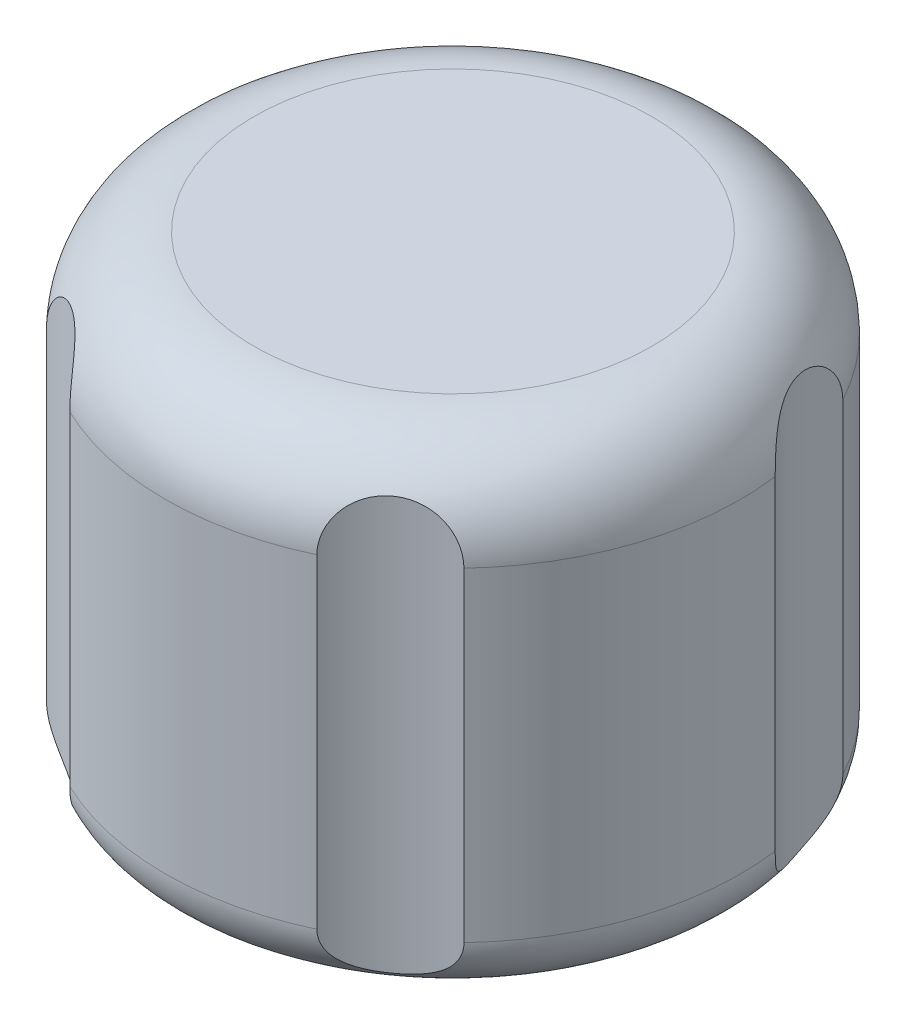
from build123d import *

# Parameters (mm, degrees)
SKETCH1_R           = 9.75
BOSS_EXTRUDE1_DEPTH = 16
SKETCH2_R           = 3
CUT_EXTRUDE1_DEPTH  = 15
SKETCH5_R           = 4.5
CUT_EXTRUDE2_DEPTH  = 4.2
FILLET1_R           = 3
FILLET2_R           = 2
SKETCH11_R          = 4.7625
CUT_EXTRUDE4_DEPTH  = 17
CIRPATTERN3_COUNT   = 5


with BuildPart() as part:
    # Sketch1 → Boss-Extrude1 (new body)
    with BuildSketch(Plane(origin=(0, 0, 0), x_dir=(1, 0, 0), z_dir=(0, 1, 0))):
        with Locations(Location((0, 0, 0), (0, 0, 90))):  # turned: the seam where the file's is
            Circle(SKETCH1_R)
    extrude(amount=BOSS_EXTRUDE1_DEPTH)

    # Sketch2 → Cut-Extrude1 (cut)
    with BuildSketch(Plane.XZ):
        with Locations(Location((0, 0, 0), (0, 0, 270))):  # turned: the seam where the file's is
            Circle(SKETCH2_R)
    extrude(amount=-CUT_EXTRUDE1_DEPTH, mode=Mode.SUBTRACT)

    # Sketch5 → Cut-Extrude2 (cut)
    with BuildSketch(Plane.XZ):
        with Locations(Location((0, 0, 0), (0, 0, 270))):  # turned: the seam where the file's is
            Circle(SKETCH5_R)
    extrude(amount=-CUT_EXTRUDE2_DEPTH, mode=Mode.SUBTRACT)

    # Fillet1
    fillet1_edges = [part.edges().sort_by_distance(p)[0] for p in [
        (0, 16, 9.75),
    ]]
    fillet(fillet1_edges, radius=FILLET1_R)

    # Fillet2
    fillet2_edges = [part.edges().sort_by_distance(p)[0] for p in [
        (0, 0, 9.75),
    ]]
    fillet(fillet2_edges, radius=FILLET2_R)

    # Sketch11 → Cut-Extrude4 (cut, through all)
    with BuildSketch(Plane(origin=(0, 16, 0), x_dir=(1, 0, 0), z_dir=(0, 1, 0))):
        with Locations((0, 14)):
            Circle(SKETCH11_R)
    cut_extrude4 = extrude(amount=-CUT_EXTRUDE4_DEPTH, mode=Mode.SUBTRACT)

    # CirPattern3: Cut-Extrude4 ×5 about axis
    cirpattern3_axis = Axis((0, 0, 0), (0, 1, 0))
    for i in range(1, CIRPATTERN3_COUNT):
        add(cut_extrude4.rotate(cirpattern3_axis, i * 360 / CIRPATTERN3_COUNT), mode=Mode.SUBTRACT)


solid = part.part
